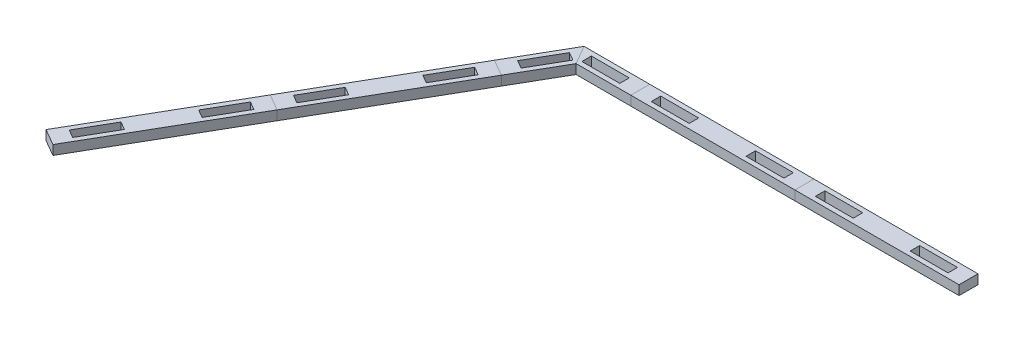
from build123d import *

# Parameters (mm, degrees)
BOSS_EXTRUDE1_DEPTH = 6.35
CUT_EXTRUDE4_DEPTH  = 111.168382488
BOSS_EXTRUDE4_DEPTH = 6.35
CIRPATTERN1_COUNT   = 2
CIRPATTERN1_ANGLE   = 60
SKETCH12_W          = 109.98522628
SKETCH12_H          = 82.55
CUT_EXTRUDE5_DEPTH  = 111.168382488
SKETCH13_W          = 25.4
SKETCH13_H          = 6.35
CUT_EXTRUDE6_DEPTH  = 64.816710194
LPATTERN1_COUNT     = 5
LPATTERN1_PITCH     = 109.985226308
LPATTERN1_2_COUNT   = 2
LPATTERN1_2_PITCH   = 109.985226308
SKETCH14_W          = 25.4
SKETCH14_H          = 6.35
CUT_EXTRUDE7_DEPTH  = 496.991504573
CUT_EXTRUDE8_DEPTH  = 431.162704792


with BuildPart() as part:
    # Sketch1 → Boss-Extrude1 (new body)
    with BuildSketch(Plane(origin=(0, 0, 0), x_dir=(1, 0, 0), z_dir=(0, 1, 0))):
        Polygon((-54.99261314, 0), (0, -31.75), (54.99261314, 0), (54.99261314, 63.5), (0, 95.25), (-54.99261314, 63.5), align=None)
    extrude(amount=-BOSS_EXTRUDE1_DEPTH)

    # Sketch10 → Cut-Extrude4 (cut, through all)
    with BuildSketch(Plane(origin=(0, 0, 0), x_dir=(1, 0, 0), z_dir=(0, 1, 0))):
        Polygon((-16.497783942, -22.225), (-7.823522628, -19.900738686), (-24.32130657, -10.375738686), (-27.49630657, -15.875), align=None)
    cut_extrude4 = extrude(amount=-CUT_EXTRUDE4_DEPTH, mode=Mode.SUBTRACT)

    # Sketch11 → Boss-Extrude4 (add)
    with BuildSketch(Plane(origin=(0, 0, 0), x_dir=(1, 0, 0), z_dir=(0, 1, 0))):
        Polygon((-27.49630657, -15.875), (-30.67130657, -21.374261314), (-47.169090512, -11.849261314), (-38.494829198, -9.525), align=None)
    boss_extrude4 = extrude(amount=-BOSS_EXTRUDE4_DEPTH)

    # CirPattern1: Cut-Extrude4, Boss-Extrude4 ×2 about axis
    cirpattern1_axis = Axis((0, 0, -31.75), (0, 1, 0))
    add([cut_extrude4.rotate(cirpattern1_axis, i * CIRPATTERN1_ANGLE / (CIRPATTERN1_COUNT - 1)) for i in range(1, CIRPATTERN1_COUNT)], mode=Mode.SUBTRACT)
    add([boss_extrude4.rotate(cirpattern1_axis, i * CIRPATTERN1_ANGLE / (CIRPATTERN1_COUNT - 1)) for i in range(1, CIRPATTERN1_COUNT)])

    # Sketch12 → Cut-Extrude5 (cut, through all)
    with BuildSketch(Plane(origin=(0, 0, 0), x_dir=(1, 0, 0), z_dir=(0, 1, 0))):
        with Locations((0, 53.975)):
            Rectangle(SKETCH12_W, SKETCH12_H)
    extrude(amount=-CUT_EXTRUDE5_DEPTH, mode=Mode.SUBTRACT)

    # Sketch13 → Cut-Extrude6 (cut, through all)
    with BuildSketch(Plane(origin=(0, 0, 0), x_dir=(1, 0, 0), z_dir=(0, 1, 0))):
        with Locations((-31.75, 6.35)):
            Rectangle(SKETCH13_W, SKETCH13_H)
        with Locations((31.75, 6.35)):
            Rectangle(SKETCH13_W, SKETCH13_H)
    extrude(amount=-CUT_EXTRUDE6_DEPTH, mode=Mode.SUBTRACT)


with BuildPart() as lpattern1_1:
    # LPattern1: pattern copy
    add(part.part.moved(Location(Vector(1, 0, 0) * (1 * LPATTERN1_PITCH))))


with BuildPart() as lpattern1_2:
    # LPattern1: pattern copy
    add(part.part.moved(Location(Vector(1, 0, 0) * (2 * LPATTERN1_PITCH))))


with BuildPart() as lpattern1_3:
    # LPattern1: pattern copy
    add(part.part.moved(Location(Vector(1, 0, 0) * (3 * LPATTERN1_PITCH))))


with BuildPart() as lpattern1_4:
    # LPattern1: pattern copy
    add(part.part.moved(Location(Vector(1, 0, 0) * (4 * LPATTERN1_PITCH))))


with BuildPart() as lpattern1_2_1:
    # LPattern1 2: pattern copy
    add(part.part.moved(Location(Vector(-1, 0, 0) * (1 * LPATTERN1_2_PITCH))))


with BuildPart() as cut_extrude7_tool:
    # Sketch14 → Cut-Extrude7 (new, through all)
    # profile 1 of 2: a face of its own
    with BuildSketch(Plane(origin=(0, 0, 0), x_dir=(1, 0, 0), z_dir=(0, 1, 0))):
        Polygon((423.44312129, -22.225), (439.940905232, -31.75), (456.438689174, -22.225), (454.11442786, -30.899261314), (470.612211802, -21.374261314), (464.262211802, -10.375738686), (480.759995744, -0.850738686), (478.43573443, -9.525), (494.933518372, 0), (494.933518372, 12.7), (428.942382604, 12.7), (415.619598662, -10.375738686), (432.117382604, -19.900738686), align=None)
        with Locations((471.690905232, 6.35)):
            Rectangle(SKETCH14_W, SKETCH14_H, mode=Mode.SUBTRACT)
    # profile 2 of 2: a face of its own
    with BuildSketch(Plane(origin=(0, 0, 0), x_dir=(1, 0, 0), z_dir=(0, 1, 0))):
        Polygon((-164.977839448, -31.75), (-109.985226308, -31.75), (-95.81170368, -30.899261314), (-79.313919738, -21.374261314), (-98.98670368, 12.7), (-164.977839448, 12.7), align=None)
    extrude(amount=-CUT_EXTRUDE7_DEPTH)


with BuildPart() as lpattern1_4_1:
    add(lpattern1_4.part)

    # Cut-Extrude7: cut by cut_extrude7_tool
    add(cut_extrude7_tool.part, mode=Mode.SUBTRACT)


with BuildPart() as lpattern1_2_1_1:
    add(lpattern1_2_1.part)

    # Cut-Extrude7: cut by cut_extrude7_tool
    add(cut_extrude7_tool.part, mode=Mode.SUBTRACT)


with BuildPart() as cut_extrude8_tool:
    # Sketch15 → Cut-Extrude8 (new, through all)
    with BuildSketch(Plane(origin=(0, 0, 0), x_dir=(1, 0, 0), z_dir=(0, 1, 0))):
        Polygon((-222.372160524, 0), (-222.372160524, -63.5), (552.327839476, -63.5), (552.327839476, 12.7), (164.977839476, 12.7), (164.977839476, 0), align=None)
    extrude(amount=-CUT_EXTRUDE8_DEPTH)


with BuildPart() as part_1:
    add(part.part)

    # Cut-Extrude8: cut by cut_extrude8_tool
    add(cut_extrude8_tool.part, mode=Mode.SUBTRACT)


with BuildPart() as lpattern1_1_1:
    add(lpattern1_1.part)

    # Cut-Extrude8: cut by cut_extrude8_tool
    add(cut_extrude8_tool.part, mode=Mode.SUBTRACT)


with BuildPart() as lpattern1_2_2:
    add(lpattern1_2.part)

    # Cut-Extrude8: cut by cut_extrude8_tool
    add(cut_extrude8_tool.part, mode=Mode.SUBTRACT)


with BuildPart() as lpattern1_3_1:
    add(lpattern1_3.part)

    # Cut-Extrude8: cut by cut_extrude8_tool
    add(cut_extrude8_tool.part, mode=Mode.SUBTRACT)


with BuildPart() as lpattern1_4_2:
    add(lpattern1_4_1.part)

    # Cut-Extrude8: cut by cut_extrude8_tool
    add(cut_extrude8_tool.part, mode=Mode.SUBTRACT)


with BuildPart() as lpattern1_2_1_2:
    add(lpattern1_2_1_1.part)

    # Cut-Extrude8: cut by cut_extrude8_tool
    add(cut_extrude8_tool.part, mode=Mode.SUBTRACT)


with BuildPart() as body_4:
    # Mirror1: mirrored copy
    add(lpattern1_2_1_2.part.mirror(Plane(origin=(-68.740766446, -6.35, 39.687500012), x_dir=(0.500000000000001, 0, 0.8660254037844382), z_dir=(0.8660254037844383, 0, -0.5000000000000009))))


with BuildPart() as body_5:
    # Mirror1 2: mirrored copy
    add(part_1.part.mirror(Plane(origin=(-68.740766446, -6.35, 39.687500012), x_dir=(0.500000000000001, 0, 0.8660254037844382), z_dir=(0.8660254037844383, 0, -0.5000000000000009))))


with BuildPart() as body_6:
    # Mirror1 3: mirrored copy
    add(lpattern1_1_1.part.mirror(Plane(origin=(-68.740766446, -6.35, 39.687500012), x_dir=(0.500000000000001, 0, 0.8660254037844382), z_dir=(0.8660254037844383, 0, -0.5000000000000009))))


solid = Compound([part_1.part, lpattern1_1_1.part, lpattern1_2_1_2.part, body_4.part, body_5.part, body_6.part])
